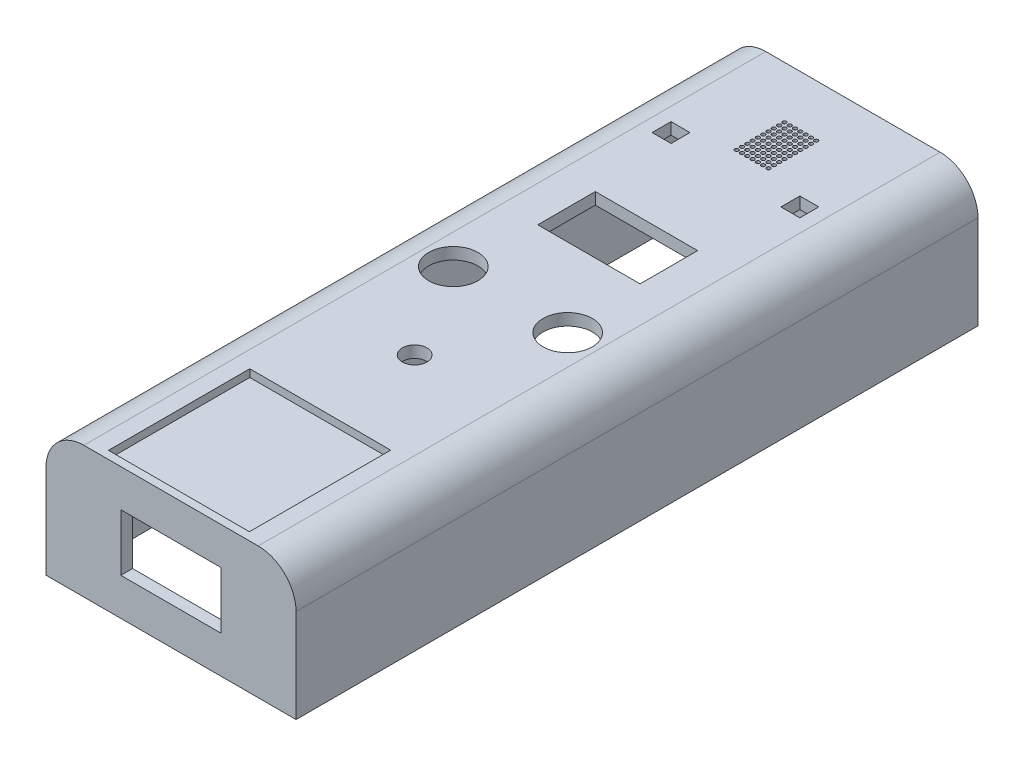
from build123d import *

# Parameters (mm, degrees)
SKETCH1_W           = 66
SKETCH1_H           = 180
BOSS_EXTRUDE1_DEPTH = 34.7
FILLET1_R           = 10
SHELL1_T            = -3.1
SKETCH4_R           = 6.5
CUT_EXTRUDE4_DEPTH  = 35.7
SKETCH2_R           = 3.25
CUT_EXTRUDE5_DEPTH  = 35.7
SKETCH5_W           = 27
SKETCH5_H           = 15.2
CUT_EXTRUDE6_DEPTH  = 35.7
SKETCH6_W           = 5
SKETCH6_H           = 5
CUT_EXTRUDE10_DEPTH = 35.7
SKETCH31_R          = 0.5
CUT_EXTRUDE11_DEPTH = 35.7
SKETCH3_W           = 37.2
SKETCH3_H           = 37.3
CUT_EXTRUDE14_DEPTH = 2
SKETCH32_W          = 26.5
SKETCH32_H          = 15
CUT_EXTRUDE16_DEPTH = 5


with BuildPart() as part:
    # Sketch1 → Boss-Extrude1 (new body)
    with BuildSketch(Plane(origin=(0, 0, 0), x_dir=(1, 0, 0), z_dir=(0, 1, 0))):
        with Locations((33, 90)):
            Rectangle(SKETCH1_W, SKETCH1_H)
    extrude(amount=BOSS_EXTRUDE1_DEPTH)

    # Fillet1
    fillet1_edges = [part.edges().sort_by_distance(p)[0] for p in [
        (66, 34.7, -90),
        (0, 34.7, -90),
    ]]
    fillet(fillet1_edges, radius=FILLET1_R)

    # Shell1
    shell1_openings = [part.faces().sort_by_distance(p)[0] for p in [
        (33, 0, -90),
    ]]
    offset(amount=SHELL1_T, openings=shell1_openings, kind=Kind.INTERSECTION)

    # Sketch4 → Cut-Extrude4 (cut, through all)
    with BuildSketch(Plane(origin=(0, 34.7, 0), x_dir=(1, 0, 0), z_dir=(0, 1, 0))):
        with Locations((48.1, 89.6)):
            Circle(SKETCH4_R)
        with Locations((17.9, 89.6)):
            Circle(SKETCH4_R)
    extrude(amount=-CUT_EXTRUDE4_DEPTH, mode=Mode.SUBTRACT)

    # Sketch2 → Cut-Extrude5 (cut, through all)
    with BuildSketch(Plane(origin=(0, 34.7, 0), x_dir=(1, 0, 0), z_dir=(0, 1, 0))):
        with Locations((33, 64.3)):
            Circle(SKETCH2_R)
    extrude(amount=-CUT_EXTRUDE5_DEPTH, mode=Mode.SUBTRACT)

    # Sketch5 → Cut-Extrude6 (cut, through all)
    with BuildSketch(Plane(origin=(0, 34.7, 0), x_dir=(1, 0, 0), z_dir=(0, 1, 0))):
        with Locations((33, 117.9)):
            Rectangle(SKETCH5_W, SKETCH5_H)
    extrude(amount=-CUT_EXTRUDE6_DEPTH, mode=Mode.SUBTRACT)

    # Sketch6 → Cut-Extrude10 (cut, through all)
    with BuildSketch(Plane(origin=(0, 34.7, 0), x_dir=(1, 0, 0), z_dir=(0, 1, 0))):
        with Locations((50, 148.979436507)):
            Rectangle(SKETCH6_W, SKETCH6_H)
        with Locations((16, 148.979436507)):
            Rectangle(SKETCH6_W, SKETCH6_H)
    extrude(amount=-CUT_EXTRUDE10_DEPTH, mode=Mode.SUBTRACT)

    # Sketch31 → Cut-Extrude11 (cut, through all)
    with BuildSketch(Plane(origin=(0, 34.7, 0), x_dir=(1, 0, 0), z_dir=(0, 1, 0))):
        with Locations((28.628571429, 166.273512362)):
            Circle(SKETCH31_R)
        with Locations((30.028571429, 166.273512362)):
            Circle(SKETCH31_R)
        with Locations((31.428571429, 166.273512362)):
            Circle(SKETCH31_R)
        with Locations((32.828571429, 166.273512362)):
            Circle(SKETCH31_R)
        with Locations((34.228571429, 166.273512362)):
            Circle(SKETCH31_R)
        with Locations((35.628571429, 166.273512362)):
            Circle(SKETCH31_R)
        with Locations((37.028571429, 166.273512362)):
            Circle(SKETCH31_R)
        with Locations((30.028571429, 164.873512362)):
            Circle(SKETCH31_R)
        with Locations((31.428571429, 164.873512362)):
            Circle(SKETCH31_R)
        with Locations((32.828571429, 164.873512362)):
            Circle(SKETCH31_R)
        with Locations((34.228571429, 164.873512362)):
            Circle(SKETCH31_R)
        with Locations((35.628571429, 164.873512362)):
            Circle(SKETCH31_R)
        with Locations((37.028571429, 164.873512362)):
            Circle(SKETCH31_R)
        with Locations((30.028571429, 163.473512362)):
            Circle(SKETCH31_R)
        with Locations((31.428571429, 163.473512362)):
            Circle(SKETCH31_R)
        with Locations((32.828571429, 163.473512362)):
            Circle(SKETCH31_R)
        with Locations((34.228571429, 163.473512362)):
            Circle(SKETCH31_R)
        with Locations((35.628571429, 163.473512362)):
            Circle(SKETCH31_R)
        with Locations((37.028571429, 163.473512362)):
            Circle(SKETCH31_R)
        with Locations((30.028571429, 162.073512362)):
            Circle(SKETCH31_R)
        with Locations((31.428571429, 162.073512362)):
            Circle(SKETCH31_R)
        with Locations((32.828571429, 162.073512362)):
            Circle(SKETCH31_R)
        with Locations((34.228571429, 162.073512362)):
            Circle(SKETCH31_R)
        with Locations((35.628571429, 162.073512362)):
            Circle(SKETCH31_R)
        with Locations((37.028571429, 162.073512362)):
            Circle(SKETCH31_R)
        with Locations((30.028571429, 160.673512362)):
            Circle(SKETCH31_R)
        with Locations((31.428571429, 160.673512362)):
            Circle(SKETCH31_R)
        with Locations((32.828571429, 160.673512362)):
            Circle(SKETCH31_R)
        with Locations((34.228571429, 160.673512362)):
            Circle(SKETCH31_R)
        with Locations((35.628571429, 160.673512362)):
            Circle(SKETCH31_R)
        with Locations((37.028571429, 160.673512362)):
            Circle(SKETCH31_R)
        with Locations((30.028571429, 159.273512362)):
            Circle(SKETCH31_R)
        with Locations((31.428571429, 159.273512362)):
            Circle(SKETCH31_R)
        with Locations((32.828571429, 159.273512362)):
            Circle(SKETCH31_R)
        with Locations((34.228571429, 159.273512362)):
            Circle(SKETCH31_R)
        with Locations((35.628571429, 159.273512362)):
            Circle(SKETCH31_R)
        with Locations((37.028571429, 159.273512362)):
            Circle(SKETCH31_R)
        with Locations((30.028571429, 157.873512362)):
            Circle(SKETCH31_R)
        with Locations((31.428571429, 157.873512362)):
            Circle(SKETCH31_R)
        with Locations((32.828571429, 157.873512362)):
            Circle(SKETCH31_R)
        with Locations((34.228571429, 157.873512362)):
            Circle(SKETCH31_R)
        with Locations((35.628571429, 157.873512362)):
            Circle(SKETCH31_R)
        with Locations((37.028571429, 157.873512362)):
            Circle(SKETCH31_R)
        with Locations((30.028571429, 156.473512362)):
            Circle(SKETCH31_R)
        with Locations((31.428571429, 156.473512362)):
            Circle(SKETCH31_R)
        with Locations((32.828571429, 156.473512362)):
            Circle(SKETCH31_R)
        with Locations((34.228571429, 156.473512362)):
            Circle(SKETCH31_R)
        with Locations((35.628571429, 156.473512362)):
            Circle(SKETCH31_R)
        with Locations((37.028571429, 156.473512362)):
            Circle(SKETCH31_R)
        with Locations((30.028571429, 155.073512362)):
            Circle(SKETCH31_R)
        with Locations((31.428571429, 155.073512362)):
            Circle(SKETCH31_R)
        with Locations((32.828571429, 155.073512362)):
            Circle(SKETCH31_R)
        with Locations((34.228571429, 155.073512362)):
            Circle(SKETCH31_R)
        with Locations((35.628571429, 155.073512362)):
            Circle(SKETCH31_R)
        with Locations((37.028571429, 155.073512362)):
            Circle(SKETCH31_R)
        with Locations((30.028571429, 153.673512362)):
            Circle(SKETCH31_R)
        with Locations((31.428571429, 153.673512362)):
            Circle(SKETCH31_R)
        with Locations((32.828571429, 153.673512362)):
            Circle(SKETCH31_R)
        with Locations((34.228571429, 153.673512362)):
            Circle(SKETCH31_R)
        with Locations((35.628571429, 153.673512362)):
            Circle(SKETCH31_R)
        with Locations((37.028571429, 153.673512362)):
            Circle(SKETCH31_R)
        with Locations((28.628571429, 164.873512362)):
            Circle(SKETCH31_R)
        with Locations((28.628571429, 163.473512362)):
            Circle(SKETCH31_R)
        with Locations((28.628571429, 162.073512362)):
            Circle(SKETCH31_R)
        with Locations((28.628571429, 160.673512362)):
            Circle(SKETCH31_R)
        with Locations((28.628571429, 159.273512362)):
            Circle(SKETCH31_R)
        with Locations((28.628571429, 157.873512362)):
            Circle(SKETCH31_R)
        with Locations((28.628571429, 156.473512362)):
            Circle(SKETCH31_R)
        with Locations((28.628571429, 155.073512362)):
            Circle(SKETCH31_R)
        with Locations((28.628571429, 153.673512362)):
            Circle(SKETCH31_R)
    extrude(amount=-CUT_EXTRUDE11_DEPTH, mode=Mode.SUBTRACT)

    # Sketch3 → Cut-Extrude14 (cut)
    with BuildSketch(Plane(origin=(0, 34.7, 0), x_dir=(1, 0, 0), z_dir=(0, 1, 0))):
        with Locations((33, 20.740021927)):
            Rectangle(SKETCH3_W, SKETCH3_H)
    extrude(amount=-CUT_EXTRUDE14_DEPTH, mode=Mode.SUBTRACT)

    # Sketch32 → Cut-Extrude16 (cut)
    with BuildSketch(Plane.XY):
        with Locations((33, 17.35)):
            Rectangle(SKETCH32_W, SKETCH32_H)
    extrude(amount=-CUT_EXTRUDE16_DEPTH, mode=Mode.SUBTRACT)


solid = part.part
